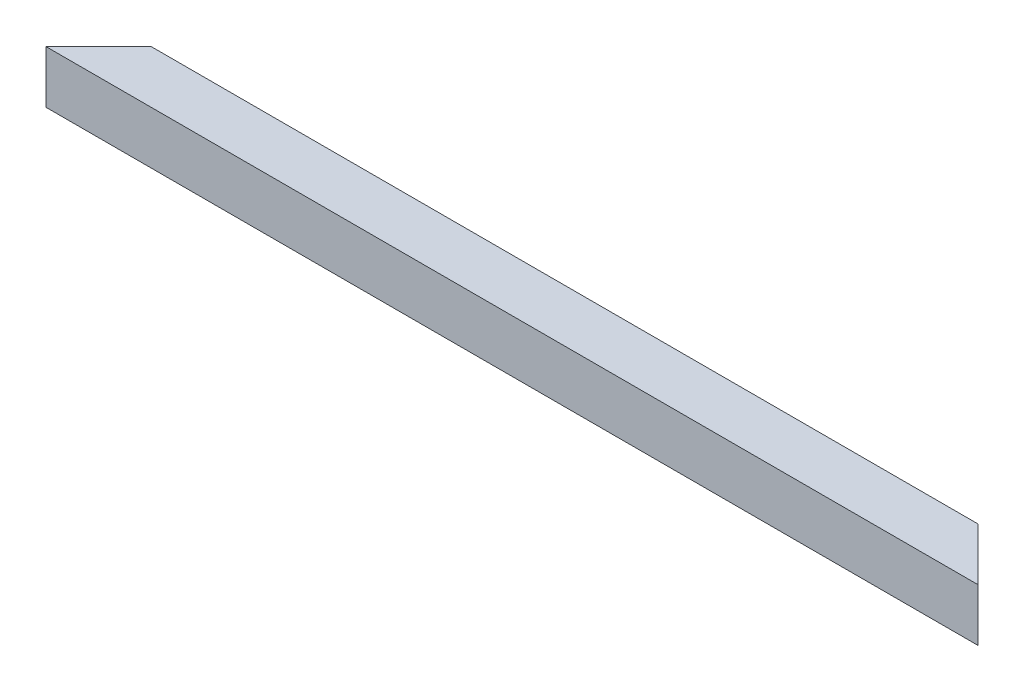
from build123d import *

# Parameters (mm, degrees)
SKETCH1_W           = 450
SKETCH1_H           = 25.4
BOSS_EXTRUDE1_DEPTH = 25.4
SKETCH2_W           = 23
SKETCH2_H           = 23
CUT_EXTRUDE1_DEPTH  = 450
CUT_EXTRUDE2_DEPTH  = 25.4


with BuildPart() as part:
    # Sketch1 → Boss-Extrude1 (new body)
    with BuildSketch(Plane(origin=(0, 0, 0), x_dir=(1, 0, 0), z_dir=(0, 1, 0))):
        with Locations((225, 12.7)):
            Rectangle(SKETCH1_W, SKETCH1_H)
    extrude(amount=BOSS_EXTRUDE1_DEPTH)

    # Sketch2 → Cut-Extrude1 (cut)
    with BuildSketch(Plane(origin=(450, 0, 0), x_dir=(0, 0, -1), z_dir=(1, 0, 0))):
        with Locations((12.7, 12.7)):
            Rectangle(SKETCH2_W, SKETCH2_H)
    extrude(amount=-CUT_EXTRUDE1_DEPTH, mode=Mode.SUBTRACT)

    # Sketch3 → Cut-Extrude2 (cut)
    with BuildSketch(Plane(origin=(0, 25.4, 0), x_dir=(1, 0, 0), z_dir=(0, 1, 0))):
        Polygon((0, 0), (25.4, 25.4), (0, 25.4), align=None)
        Polygon((450, 0), (424.6, 25.4), (450, 25.4), align=None)
    extrude(amount=-CUT_EXTRUDE2_DEPTH, mode=Mode.SUBTRACT)


solid = part.part
